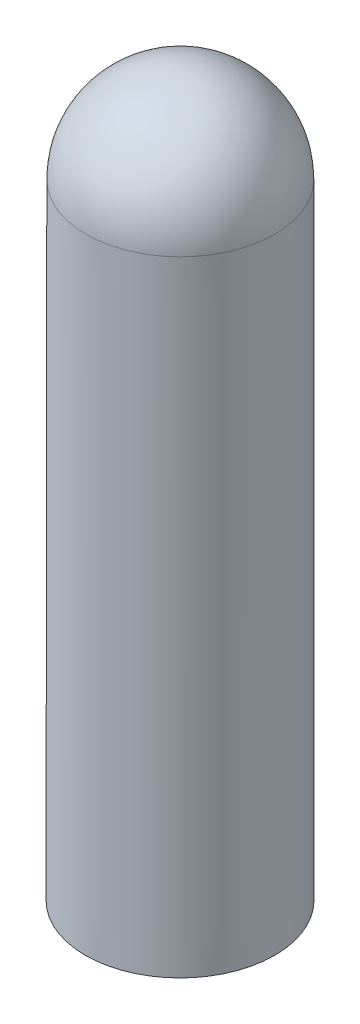
from build123d import *


with BuildPart() as part:
    # Sketch1 → Revolve1 (revolve)
    with BuildSketch(Plane.XY):
        with BuildLine():
            Line((1.99620494, -2.003791459), (1.99620494, -15.214242059))
            Line((1.99620494, -15.214242059), (-0.007590119, -15.214242059))
            Line((-0.007590119, -15.214242059), (0, 0))
            ThreePointArc((0, 0), (1.413101797, -0.588467624), (1.99620494, -2.003791459))
        make_face()
    revolve(axis=Axis((-0.007590119, -15.214242059, 0), (0.000498882, 0.999999876, 0)))


solid = part.part
